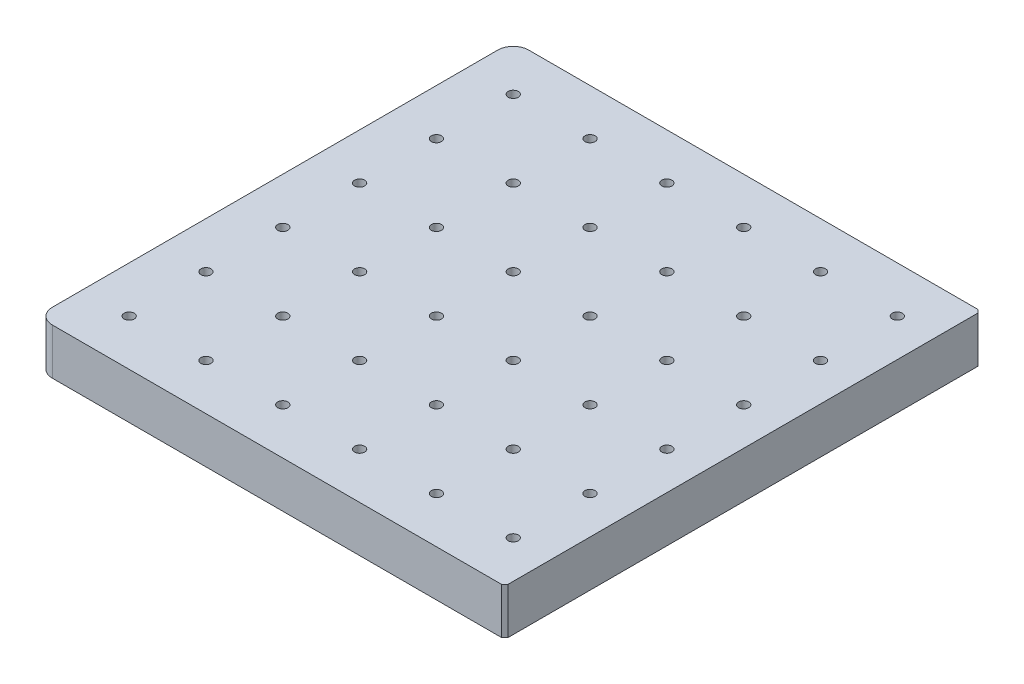
from build123d import *

# Parameters (mm, degrees)
SKETCH1_W                  = 152.25
SKETCH1_H                  = 155
BOSS_EXTRUDE1_DEPTH        = 15
SKETCH2_R                  = 1.65
CUT_EXTRUDE1_DEPTH         = 16
FILLET1_R                  = 5
CHAMFER1_SIZE              = 1
CUT_EXTRUDE2_DEPTH         = 3
LPATTERN1_COUNT            = 6
LPATTERN1_PITCH            = 25
LPATTERN2_COUNT            = 6
LPATTERN2_PITCH            = 25
LPATTERN2_COPY_1_SKETCH_R  = 1.65
LPATTERN2_COPY_1_DEPTH     = 16
LPATTERN2_COPY_2_SKETCH_R  = 1.65
LPATTERN2_COPY_2_DEPTH     = 16
LPATTERN2_COPY_3_SKETCH_R  = 1.65
LPATTERN2_COPY_3_DEPTH     = 16
LPATTERN2_COPY_4_SKETCH_R  = 1.65
LPATTERN2_COPY_4_DEPTH     = 16
LPATTERN2_COPY_5_SKETCH_R  = 1.65
LPATTERN2_COPY_5_DEPTH     = 16
LPATTERN2_COPY_6_SKETCH_R  = 1.65
LPATTERN2_COPY_6_DEPTH     = 16
LPATTERN2_COPY_7_SKETCH_R  = 1.65
LPATTERN2_COPY_7_DEPTH     = 16
LPATTERN2_COPY_8_SKETCH_R  = 1.65
LPATTERN2_COPY_8_DEPTH     = 16
LPATTERN2_COPY_9_SKETCH_R  = 1.65
LPATTERN2_COPY_9_DEPTH     = 16
LPATTERN2_COPY_10_SKETCH_R = 1.65
LPATTERN2_COPY_10_DEPTH    = 16
LPATTERN2_COPY_11_SKETCH_R = 1.65
LPATTERN2_COPY_11_DEPTH    = 16
LPATTERN2_COPY_12_SKETCH_R = 1.65
LPATTERN2_COPY_12_DEPTH    = 16
LPATTERN2_COPY_13_SKETCH_R = 1.65
LPATTERN2_COPY_13_DEPTH    = 16
LPATTERN2_COPY_14_SKETCH_R = 1.65
LPATTERN2_COPY_14_DEPTH    = 16
LPATTERN2_COPY_15_SKETCH_R = 1.65
LPATTERN2_COPY_15_DEPTH    = 16
LPATTERN2_COPY_16_SKETCH_R = 1.65
LPATTERN2_COPY_16_DEPTH    = 16
LPATTERN2_COPY_17_SKETCH_R = 1.65
LPATTERN2_COPY_17_DEPTH    = 16
LPATTERN2_COPY_18_SKETCH_R = 1.65
LPATTERN2_COPY_18_DEPTH    = 16
LPATTERN2_COPY_19_SKETCH_R = 1.65
LPATTERN2_COPY_19_DEPTH    = 16
LPATTERN2_COPY_20_SKETCH_R = 1.65
LPATTERN2_COPY_20_DEPTH    = 16
LPATTERN2_COPY_21_SKETCH_R = 1.65
LPATTERN2_COPY_21_DEPTH    = 16
LPATTERN2_COPY_22_SKETCH_R = 1.65
LPATTERN2_COPY_22_DEPTH    = 16
LPATTERN2_COPY_23_SKETCH_R = 1.65
LPATTERN2_COPY_23_DEPTH    = 16
LPATTERN2_COPY_24_SKETCH_R = 1.65
LPATTERN2_COPY_24_DEPTH    = 16
LPATTERN2_COPY_25_SKETCH_R = 1.65
LPATTERN2_COPY_25_DEPTH    = 16
LPATTERN2_COPY_26_DEPTH    = 3
LPATTERN2_COPY_27_DEPTH    = 3
LPATTERN2_COPY_28_DEPTH    = 3
LPATTERN2_COPY_29_DEPTH    = 3
LPATTERN2_COPY_30_DEPTH    = 3
LPATTERN2_COPY_31_DEPTH    = 3
LPATTERN2_COPY_32_DEPTH    = 3
LPATTERN2_COPY_33_DEPTH    = 3
LPATTERN2_COPY_34_DEPTH    = 3
LPATTERN2_COPY_35_DEPTH    = 3
LPATTERN2_COPY_36_DEPTH    = 3
LPATTERN2_COPY_37_DEPTH    = 3
LPATTERN2_COPY_38_DEPTH    = 3
LPATTERN2_COPY_39_DEPTH    = 3
LPATTERN2_COPY_40_DEPTH    = 3
LPATTERN2_COPY_41_DEPTH    = 3
LPATTERN2_COPY_42_DEPTH    = 3
LPATTERN2_COPY_43_DEPTH    = 3
LPATTERN2_COPY_44_DEPTH    = 3
LPATTERN2_COPY_45_DEPTH    = 3
LPATTERN2_COPY_46_DEPTH    = 3
LPATTERN2_COPY_47_DEPTH    = 3
LPATTERN2_COPY_48_DEPTH    = 3
LPATTERN2_COPY_49_DEPTH    = 3
LPATTERN2_COPY_50_DEPTH    = 3


with BuildPart() as part:
    # Sketch1 → Boss-Extrude1 (new body)
    with BuildSketch(Plane(origin=(0, 0, 0), x_dir=(1, 0, 0), z_dir=(0, 1, 0))):
        Rectangle(SKETCH1_W, SKETCH1_H)
    extrude(amount=BOSS_EXTRUDE1_DEPTH)

    # Sketch2 → Cut-Extrude1 (cut, through all)
    with BuildSketch(Plane(origin=(0, 15, 0), x_dir=(1, 0, 0), z_dir=(0, 1, 0))):
        with Locations((-61.125, -62.5)):
            Circle(SKETCH2_R)
    cut_extrude1 = extrude(amount=-CUT_EXTRUDE1_DEPTH, mode=Mode.SUBTRACT)

    # Fillet1
    fillet1_edges = [part.edges().sort_by_distance(p)[0] for p in [
        (-76.125, 7.5, -77.5),
        (-76.125, 7.5, 77.5),
    ]]
    fillet(fillet1_edges, radius=FILLET1_R)

    # Chamfer1
    chamfer1_edges = [part.edges().sort_by_distance(p)[0] for p in [
        (76.125, 7.5, -77.5),
        (76.125, 7.5, 77.5),
    ]]
    chamfer(chamfer1_edges, length=CHAMFER1_SIZE)

    # Sketch3 → Cut-Extrude2 (cut)
    with BuildSketch(Plane(origin=(0, 6, 0), x_dir=(-1, 0, 0), z_dir=(0, -1, 0))):
        Polygon((64.589101615, -62.5), (62.857050808, -59.5), (59.392949192, -59.5), (57.660898385, -62.5), (59.392949192, -65.5), (62.857050808, -65.5), align=None)
    cut_extrude2 = extrude(amount=-CUT_EXTRUDE2_DEPTH, mode=Mode.SUBTRACT)

    # LPattern1: Cut-Extrude1, Cut-Extrude2 ×6
    with Locations(*[(i * LPATTERN1_PITCH, 0, 0) for i in range(1, LPATTERN1_COUNT)]):
        add(cut_extrude1, mode=Mode.SUBTRACT)
        add(cut_extrude2, mode=Mode.SUBTRACT)

    # LPattern2: Cut-Extrude1, Cut-Extrude2 ×6
    with Locations(*[(0, 0, -i * LPATTERN2_PITCH) for i in range(1, LPATTERN2_COUNT)]):
        add(cut_extrude1, mode=Mode.SUBTRACT)
        add(cut_extrude2, mode=Mode.SUBTRACT)

    # LPattern2 copy 1 sketch → LPattern2 copy 1 (cut, through all)
    with BuildSketch(Plane(origin=(25, 15, -25), x_dir=(1, 0, 0), z_dir=(0, 1, 0))):
        with Locations((-61.125, -62.5)):
            Circle(LPATTERN2_COPY_1_SKETCH_R)
    extrude(amount=-LPATTERN2_COPY_1_DEPTH, mode=Mode.SUBTRACT)

    # LPattern2 copy 2 sketch → LPattern2 copy 2 (cut, through all)
    with BuildSketch(Plane(origin=(25, 15, -50), x_dir=(1, 0, 0), z_dir=(0, 1, 0))):
        with Locations((-61.125, -62.5)):
            Circle(LPATTERN2_COPY_2_SKETCH_R)
    extrude(amount=-LPATTERN2_COPY_2_DEPTH, mode=Mode.SUBTRACT)

    # LPattern2 copy 3 sketch → LPattern2 copy 3 (cut, through all)
    with BuildSketch(Plane(origin=(25, 15, -75), x_dir=(1, 0, 0), z_dir=(0, 1, 0))):
        with Locations((-61.125, -62.5)):
            Circle(LPATTERN2_COPY_3_SKETCH_R)
    extrude(amount=-LPATTERN2_COPY_3_DEPTH, mode=Mode.SUBTRACT)

    # LPattern2 copy 4 sketch → LPattern2 copy 4 (cut, through all)
    with BuildSketch(Plane(origin=(25, 15, -100), x_dir=(1, 0, 0), z_dir=(0, 1, 0))):
        with Locations((-61.125, -62.5)):
            Circle(LPATTERN2_COPY_4_SKETCH_R)
    extrude(amount=-LPATTERN2_COPY_4_DEPTH, mode=Mode.SUBTRACT)

    # LPattern2 copy 5 sketch → LPattern2 copy 5 (cut, through all)
    with BuildSketch(Plane(origin=(25, 15, -125), x_dir=(1, 0, 0), z_dir=(0, 1, 0))):
        with Locations((-61.125, -62.5)):
            Circle(LPATTERN2_COPY_5_SKETCH_R)
    extrude(amount=-LPATTERN2_COPY_5_DEPTH, mode=Mode.SUBTRACT)

    # LPattern2 copy 6 sketch → LPattern2 copy 6 (cut, through all)
    with BuildSketch(Plane(origin=(50, 15, -25), x_dir=(1, 0, 0), z_dir=(0, 1, 0))):
        with Locations((-61.125, -62.5)):
            Circle(LPATTERN2_COPY_6_SKETCH_R)
    extrude(amount=-LPATTERN2_COPY_6_DEPTH, mode=Mode.SUBTRACT)

    # LPattern2 copy 7 sketch → LPattern2 copy 7 (cut, through all)
    with BuildSketch(Plane(origin=(50, 15, -50), x_dir=(1, 0, 0), z_dir=(0, 1, 0))):
        with Locations((-61.125, -62.5)):
            Circle(LPATTERN2_COPY_7_SKETCH_R)
    extrude(amount=-LPATTERN2_COPY_7_DEPTH, mode=Mode.SUBTRACT)

    # LPattern2 copy 8 sketch → LPattern2 copy 8 (cut, through all)
    with BuildSketch(Plane(origin=(50, 15, -75), x_dir=(1, 0, 0), z_dir=(0, 1, 0))):
        with Locations((-61.125, -62.5)):
            Circle(LPATTERN2_COPY_8_SKETCH_R)
    extrude(amount=-LPATTERN2_COPY_8_DEPTH, mode=Mode.SUBTRACT)

    # LPattern2 copy 9 sketch → LPattern2 copy 9 (cut, through all)
    with BuildSketch(Plane(origin=(50, 15, -100), x_dir=(1, 0, 0), z_dir=(0, 1, 0))):
        with Locations((-61.125, -62.5)):
            Circle(LPATTERN2_COPY_9_SKETCH_R)
    extrude(amount=-LPATTERN2_COPY_9_DEPTH, mode=Mode.SUBTRACT)

    # LPattern2 copy 10 sketch → LPattern2 copy 10 (cut, through all)
    with BuildSketch(Plane(origin=(50, 15, -125), x_dir=(1, 0, 0), z_dir=(0, 1, 0))):
        with Locations((-61.125, -62.5)):
            Circle(LPATTERN2_COPY_10_SKETCH_R)
    extrude(amount=-LPATTERN2_COPY_10_DEPTH, mode=Mode.SUBTRACT)

    # LPattern2 copy 11 sketch → LPattern2 copy 11 (cut, through all)
    with BuildSketch(Plane(origin=(75, 15, -25), x_dir=(1, 0, 0), z_dir=(0, 1, 0))):
        with Locations((-61.125, -62.5)):
            Circle(LPATTERN2_COPY_11_SKETCH_R)
    extrude(amount=-LPATTERN2_COPY_11_DEPTH, mode=Mode.SUBTRACT)

    # LPattern2 copy 12 sketch → LPattern2 copy 12 (cut, through all)
    with BuildSketch(Plane(origin=(75, 15, -50), x_dir=(1, 0, 0), z_dir=(0, 1, 0))):
        with Locations((-61.125, -62.5)):
            Circle(LPATTERN2_COPY_12_SKETCH_R)
    extrude(amount=-LPATTERN2_COPY_12_DEPTH, mode=Mode.SUBTRACT)

    # LPattern2 copy 13 sketch → LPattern2 copy 13 (cut, through all)
    with BuildSketch(Plane(origin=(75, 15, -75), x_dir=(1, 0, 0), z_dir=(0, 1, 0))):
        with Locations((-61.125, -62.5)):
            Circle(LPATTERN2_COPY_13_SKETCH_R)
    extrude(amount=-LPATTERN2_COPY_13_DEPTH, mode=Mode.SUBTRACT)

    # LPattern2 copy 14 sketch → LPattern2 copy 14 (cut, through all)
    with BuildSketch(Plane(origin=(75, 15, -100), x_dir=(1, 0, 0), z_dir=(0, 1, 0))):
        with Locations((-61.125, -62.5)):
            Circle(LPATTERN2_COPY_14_SKETCH_R)
    extrude(amount=-LPATTERN2_COPY_14_DEPTH, mode=Mode.SUBTRACT)

    # LPattern2 copy 15 sketch → LPattern2 copy 15 (cut, through all)
    with BuildSketch(Plane(origin=(75, 15, -125), x_dir=(1, 0, 0), z_dir=(0, 1, 0))):
        with Locations((-61.125, -62.5)):
            Circle(LPATTERN2_COPY_15_SKETCH_R)
    extrude(amount=-LPATTERN2_COPY_15_DEPTH, mode=Mode.SUBTRACT)

    # LPattern2 copy 16 sketch → LPattern2 copy 16 (cut, through all)
    with BuildSketch(Plane(origin=(100, 15, -25), x_dir=(1, 0, 0), z_dir=(0, 1, 0))):
        with Locations((-61.125, -62.5)):
            Circle(LPATTERN2_COPY_16_SKETCH_R)
    extrude(amount=-LPATTERN2_COPY_16_DEPTH, mode=Mode.SUBTRACT)

    # LPattern2 copy 17 sketch → LPattern2 copy 17 (cut, through all)
    with BuildSketch(Plane(origin=(100, 15, -50), x_dir=(1, 0, 0), z_dir=(0, 1, 0))):
        with Locations((-61.125, -62.5)):
            Circle(LPATTERN2_COPY_17_SKETCH_R)
    extrude(amount=-LPATTERN2_COPY_17_DEPTH, mode=Mode.SUBTRACT)

    # LPattern2 copy 18 sketch → LPattern2 copy 18 (cut, through all)
    with BuildSketch(Plane(origin=(100, 15, -75), x_dir=(1, 0, 0), z_dir=(0, 1, 0))):
        with Locations((-61.125, -62.5)):
            Circle(LPATTERN2_COPY_18_SKETCH_R)
    extrude(amount=-LPATTERN2_COPY_18_DEPTH, mode=Mode.SUBTRACT)

    # LPattern2 copy 19 sketch → LPattern2 copy 19 (cut, through all)
    with BuildSketch(Plane(origin=(100, 15, -100), x_dir=(1, 0, 0), z_dir=(0, 1, 0))):
        with Locations((-61.125, -62.5)):
            Circle(LPATTERN2_COPY_19_SKETCH_R)
    extrude(amount=-LPATTERN2_COPY_19_DEPTH, mode=Mode.SUBTRACT)

    # LPattern2 copy 20 sketch → LPattern2 copy 20 (cut, through all)
    with BuildSketch(Plane(origin=(100, 15, -125), x_dir=(1, 0, 0), z_dir=(0, 1, 0))):
        with Locations((-61.125, -62.5)):
            Circle(LPATTERN2_COPY_20_SKETCH_R)
    extrude(amount=-LPATTERN2_COPY_20_DEPTH, mode=Mode.SUBTRACT)

    # LPattern2 copy 21 sketch → LPattern2 copy 21 (cut, through all)
    with BuildSketch(Plane(origin=(125, 15, -25), x_dir=(1, 0, 0), z_dir=(0, 1, 0))):
        with Locations((-61.125, -62.5)):
            Circle(LPATTERN2_COPY_21_SKETCH_R)
    extrude(amount=-LPATTERN2_COPY_21_DEPTH, mode=Mode.SUBTRACT)

    # LPattern2 copy 22 sketch → LPattern2 copy 22 (cut, through all)
    with BuildSketch(Plane(origin=(125, 15, -50), x_dir=(1, 0, 0), z_dir=(0, 1, 0))):
        with Locations((-61.125, -62.5)):
            Circle(LPATTERN2_COPY_22_SKETCH_R)
    extrude(amount=-LPATTERN2_COPY_22_DEPTH, mode=Mode.SUBTRACT)

    # LPattern2 copy 23 sketch → LPattern2 copy 23 (cut, through all)
    with BuildSketch(Plane(origin=(125, 15, -75), x_dir=(1, 0, 0), z_dir=(0, 1, 0))):
        with Locations((-61.125, -62.5)):
            Circle(LPATTERN2_COPY_23_SKETCH_R)
    extrude(amount=-LPATTERN2_COPY_23_DEPTH, mode=Mode.SUBTRACT)

    # LPattern2 copy 24 sketch → LPattern2 copy 24 (cut, through all)
    with BuildSketch(Plane(origin=(125, 15, -100), x_dir=(1, 0, 0), z_dir=(0, 1, 0))):
        with Locations((-61.125, -62.5)):
            Circle(LPATTERN2_COPY_24_SKETCH_R)
    extrude(amount=-LPATTERN2_COPY_24_DEPTH, mode=Mode.SUBTRACT)

    # LPattern2 copy 25 sketch → LPattern2 copy 25 (cut, through all)
    with BuildSketch(Plane(origin=(125, 15, -125), x_dir=(1, 0, 0), z_dir=(0, 1, 0))):
        with Locations((-61.125, -62.5)):
            Circle(LPATTERN2_COPY_25_SKETCH_R)
    extrude(amount=-LPATTERN2_COPY_25_DEPTH, mode=Mode.SUBTRACT)

    # LPattern2 copy 26 sketch → LPattern2 copy 26 (cut)
    with BuildSketch(Plane(origin=(25, 6, -25), x_dir=(-1, 0, 0), z_dir=(0, -1, 0))):
        Polygon((64.589101615, -62.5), (62.857050808, -59.5), (59.392949192, -59.5), (57.660898385, -62.5), (59.392949192, -65.5), (62.857050808, -65.5), align=None)
    extrude(amount=-LPATTERN2_COPY_26_DEPTH, mode=Mode.SUBTRACT)

    # LPattern2 copy 27 sketch → LPattern2 copy 27 (cut)
    with BuildSketch(Plane(origin=(25, 6, -50), x_dir=(-1, 0, 0), z_dir=(0, -1, 0))):
        Polygon((64.589101615, -62.5), (62.857050808, -59.5), (59.392949192, -59.5), (57.660898385, -62.5), (59.392949192, -65.5), (62.857050808, -65.5), align=None)
    extrude(amount=-LPATTERN2_COPY_27_DEPTH, mode=Mode.SUBTRACT)

    # LPattern2 copy 28 sketch → LPattern2 copy 28 (cut)
    with BuildSketch(Plane(origin=(25, 6, -75), x_dir=(-1, 0, 0), z_dir=(0, -1, 0))):
        Polygon((64.589101615, -62.5), (62.857050808, -59.5), (59.392949192, -59.5), (57.660898385, -62.5), (59.392949192, -65.5), (62.857050808, -65.5), align=None)
    extrude(amount=-LPATTERN2_COPY_28_DEPTH, mode=Mode.SUBTRACT)

    # LPattern2 copy 29 sketch → LPattern2 copy 29 (cut)
    with BuildSketch(Plane(origin=(25, 6, -100), x_dir=(-1, 0, 0), z_dir=(0, -1, 0))):
        Polygon((64.589101615, -62.5), (62.857050808, -59.5), (59.392949192, -59.5), (57.660898385, -62.5), (59.392949192, -65.5), (62.857050808, -65.5), align=None)
    extrude(amount=-LPATTERN2_COPY_29_DEPTH, mode=Mode.SUBTRACT)

    # LPattern2 copy 30 sketch → LPattern2 copy 30 (cut)
    with BuildSketch(Plane(origin=(25, 6, -125), x_dir=(-1, 0, 0), z_dir=(0, -1, 0))):
        Polygon((64.589101615, -62.5), (62.857050808, -59.5), (59.392949192, -59.5), (57.660898385, -62.5), (59.392949192, -65.5), (62.857050808, -65.5), align=None)
    extrude(amount=-LPATTERN2_COPY_30_DEPTH, mode=Mode.SUBTRACT)

    # LPattern2 copy 31 sketch → LPattern2 copy 31 (cut)
    with BuildSketch(Plane(origin=(50, 6, -25), x_dir=(-1, 0, 0), z_dir=(0, -1, 0))):
        Polygon((64.589101615, -62.5), (62.857050808, -59.5), (59.392949192, -59.5), (57.660898385, -62.5), (59.392949192, -65.5), (62.857050808, -65.5), align=None)
    extrude(amount=-LPATTERN2_COPY_31_DEPTH, mode=Mode.SUBTRACT)

    # LPattern2 copy 32 sketch → LPattern2 copy 32 (cut)
    with BuildSketch(Plane(origin=(50, 6, -50), x_dir=(-1, 0, 0), z_dir=(0, -1, 0))):
        Polygon((64.589101615, -62.5), (62.857050808, -59.5), (59.392949192, -59.5), (57.660898385, -62.5), (59.392949192, -65.5), (62.857050808, -65.5), align=None)
    extrude(amount=-LPATTERN2_COPY_32_DEPTH, mode=Mode.SUBTRACT)

    # LPattern2 copy 33 sketch → LPattern2 copy 33 (cut)
    with BuildSketch(Plane(origin=(50, 6, -75), x_dir=(-1, 0, 0), z_dir=(0, -1, 0))):
        Polygon((64.589101615, -62.5), (62.857050808, -59.5), (59.392949192, -59.5), (57.660898385, -62.5), (59.392949192, -65.5), (62.857050808, -65.5), align=None)
    extrude(amount=-LPATTERN2_COPY_33_DEPTH, mode=Mode.SUBTRACT)

    # LPattern2 copy 34 sketch → LPattern2 copy 34 (cut)
    with BuildSketch(Plane(origin=(50, 6, -100), x_dir=(-1, 0, 0), z_dir=(0, -1, 0))):
        Polygon((64.589101615, -62.5), (62.857050808, -59.5), (59.392949192, -59.5), (57.660898385, -62.5), (59.392949192, -65.5), (62.857050808, -65.5), align=None)
    extrude(amount=-LPATTERN2_COPY_34_DEPTH, mode=Mode.SUBTRACT)

    # LPattern2 copy 35 sketch → LPattern2 copy 35 (cut)
    with BuildSketch(Plane(origin=(50, 6, -125), x_dir=(-1, 0, 0), z_dir=(0, -1, 0))):
        Polygon((64.589101615, -62.5), (62.857050808, -59.5), (59.392949192, -59.5), (57.660898385, -62.5), (59.392949192, -65.5), (62.857050808, -65.5), align=None)
    extrude(amount=-LPATTERN2_COPY_35_DEPTH, mode=Mode.SUBTRACT)

    # LPattern2 copy 36 sketch → LPattern2 copy 36 (cut)
    with BuildSketch(Plane(origin=(75, 6, -25), x_dir=(-1, 0, 0), z_dir=(0, -1, 0))):
        Polygon((64.589101615, -62.5), (62.857050808, -59.5), (59.392949192, -59.5), (57.660898385, -62.5), (59.392949192, -65.5), (62.857050808, -65.5), align=None)
    extrude(amount=-LPATTERN2_COPY_36_DEPTH, mode=Mode.SUBTRACT)

    # LPattern2 copy 37 sketch → LPattern2 copy 37 (cut)
    with BuildSketch(Plane(origin=(75, 6, -50), x_dir=(-1, 0, 0), z_dir=(0, -1, 0))):
        Polygon((64.589101615, -62.5), (62.857050808, -59.5), (59.392949192, -59.5), (57.660898385, -62.5), (59.392949192, -65.5), (62.857050808, -65.5), align=None)
    extrude(amount=-LPATTERN2_COPY_37_DEPTH, mode=Mode.SUBTRACT)

    # LPattern2 copy 38 sketch → LPattern2 copy 38 (cut)
    with BuildSketch(Plane(origin=(75, 6, -75), x_dir=(-1, 0, 0), z_dir=(0, -1, 0))):
        Polygon((64.589101615, -62.5), (62.857050808, -59.5), (59.392949192, -59.5), (57.660898385, -62.5), (59.392949192, -65.5), (62.857050808, -65.5), align=None)
    extrude(amount=-LPATTERN2_COPY_38_DEPTH, mode=Mode.SUBTRACT)

    # LPattern2 copy 39 sketch → LPattern2 copy 39 (cut)
    with BuildSketch(Plane(origin=(75, 6, -100), x_dir=(-1, 0, 0), z_dir=(0, -1, 0))):
        Polygon((64.589101615, -62.5), (62.857050808, -59.5), (59.392949192, -59.5), (57.660898385, -62.5), (59.392949192, -65.5), (62.857050808, -65.5), align=None)
    extrude(amount=-LPATTERN2_COPY_39_DEPTH, mode=Mode.SUBTRACT)

    # LPattern2 copy 40 sketch → LPattern2 copy 40 (cut)
    with BuildSketch(Plane(origin=(75, 6, -125), x_dir=(-1, 0, 0), z_dir=(0, -1, 0))):
        Polygon((64.589101615, -62.5), (62.857050808, -59.5), (59.392949192, -59.5), (57.660898385, -62.5), (59.392949192, -65.5), (62.857050808, -65.5), align=None)
    extrude(amount=-LPATTERN2_COPY_40_DEPTH, mode=Mode.SUBTRACT)

    # LPattern2 copy 41 sketch → LPattern2 copy 41 (cut)
    with BuildSketch(Plane(origin=(100, 6, -25), x_dir=(-1, 0, 0), z_dir=(0, -1, 0))):
        Polygon((64.589101615, -62.5), (62.857050808, -59.5), (59.392949192, -59.5), (57.660898385, -62.5), (59.392949192, -65.5), (62.857050808, -65.5), align=None)
    extrude(amount=-LPATTERN2_COPY_41_DEPTH, mode=Mode.SUBTRACT)

    # LPattern2 copy 42 sketch → LPattern2 copy 42 (cut)
    with BuildSketch(Plane(origin=(100, 6, -50), x_dir=(-1, 0, 0), z_dir=(0, -1, 0))):
        Polygon((64.589101615, -62.5), (62.857050808, -59.5), (59.392949192, -59.5), (57.660898385, -62.5), (59.392949192, -65.5), (62.857050808, -65.5), align=None)
    extrude(amount=-LPATTERN2_COPY_42_DEPTH, mode=Mode.SUBTRACT)

    # LPattern2 copy 43 sketch → LPattern2 copy 43 (cut)
    with BuildSketch(Plane(origin=(100, 6, -75), x_dir=(-1, 0, 0), z_dir=(0, -1, 0))):
        Polygon((64.589101615, -62.5), (62.857050808, -59.5), (59.392949192, -59.5), (57.660898385, -62.5), (59.392949192, -65.5), (62.857050808, -65.5), align=None)
    extrude(amount=-LPATTERN2_COPY_43_DEPTH, mode=Mode.SUBTRACT)

    # LPattern2 copy 44 sketch → LPattern2 copy 44 (cut)
    with BuildSketch(Plane(origin=(100, 6, -100), x_dir=(-1, 0, 0), z_dir=(0, -1, 0))):
        Polygon((64.589101615, -62.5), (62.857050808, -59.5), (59.392949192, -59.5), (57.660898385, -62.5), (59.392949192, -65.5), (62.857050808, -65.5), align=None)
    extrude(amount=-LPATTERN2_COPY_44_DEPTH, mode=Mode.SUBTRACT)

    # LPattern2 copy 45 sketch → LPattern2 copy 45 (cut)
    with BuildSketch(Plane(origin=(100, 6, -125), x_dir=(-1, 0, 0), z_dir=(0, -1, 0))):
        Polygon((64.589101615, -62.5), (62.857050808, -59.5), (59.392949192, -59.5), (57.660898385, -62.5), (59.392949192, -65.5), (62.857050808, -65.5), align=None)
    extrude(amount=-LPATTERN2_COPY_45_DEPTH, mode=Mode.SUBTRACT)

    # LPattern2 copy 46 sketch → LPattern2 copy 46 (cut)
    with BuildSketch(Plane(origin=(125, 6, -25), x_dir=(-1, 0, 0), z_dir=(0, -1, 0))):
        Polygon((64.589101615, -62.5), (62.857050808, -59.5), (59.392949192, -59.5), (57.660898385, -62.5), (59.392949192, -65.5), (62.857050808, -65.5), align=None)
    extrude(amount=-LPATTERN2_COPY_46_DEPTH, mode=Mode.SUBTRACT)

    # LPattern2 copy 47 sketch → LPattern2 copy 47 (cut)
    with BuildSketch(Plane(origin=(125, 6, -50), x_dir=(-1, 0, 0), z_dir=(0, -1, 0))):
        Polygon((64.589101615, -62.5), (62.857050808, -59.5), (59.392949192, -59.5), (57.660898385, -62.5), (59.392949192, -65.5), (62.857050808, -65.5), align=None)
    extrude(amount=-LPATTERN2_COPY_47_DEPTH, mode=Mode.SUBTRACT)

    # LPattern2 copy 48 sketch → LPattern2 copy 48 (cut)
    with BuildSketch(Plane(origin=(125, 6, -75), x_dir=(-1, 0, 0), z_dir=(0, -1, 0))):
        Polygon((64.589101615, -62.5), (62.857050808, -59.5), (59.392949192, -59.5), (57.660898385, -62.5), (59.392949192, -65.5), (62.857050808, -65.5), align=None)
    extrude(amount=-LPATTERN2_COPY_48_DEPTH, mode=Mode.SUBTRACT)

    # LPattern2 copy 49 sketch → LPattern2 copy 49 (cut)
    with BuildSketch(Plane(origin=(125, 6, -100), x_dir=(-1, 0, 0), z_dir=(0, -1, 0))):
        Polygon((64.589101615, -62.5), (62.857050808, -59.5), (59.392949192, -59.5), (57.660898385, -62.5), (59.392949192, -65.5), (62.857050808, -65.5), align=None)
    extrude(amount=-LPATTERN2_COPY_49_DEPTH, mode=Mode.SUBTRACT)

    # LPattern2 copy 50 sketch → LPattern2 copy 50 (cut)
    with BuildSketch(Plane(origin=(125, 6, -125), x_dir=(-1, 0, 0), z_dir=(0, -1, 0))):
        Polygon((64.589101615, -62.5), (62.857050808, -59.5), (59.392949192, -59.5), (57.660898385, -62.5), (59.392949192, -65.5), (62.857050808, -65.5), align=None)
    extrude(amount=-LPATTERN2_COPY_50_DEPTH, mode=Mode.SUBTRACT)


solid = part.part
